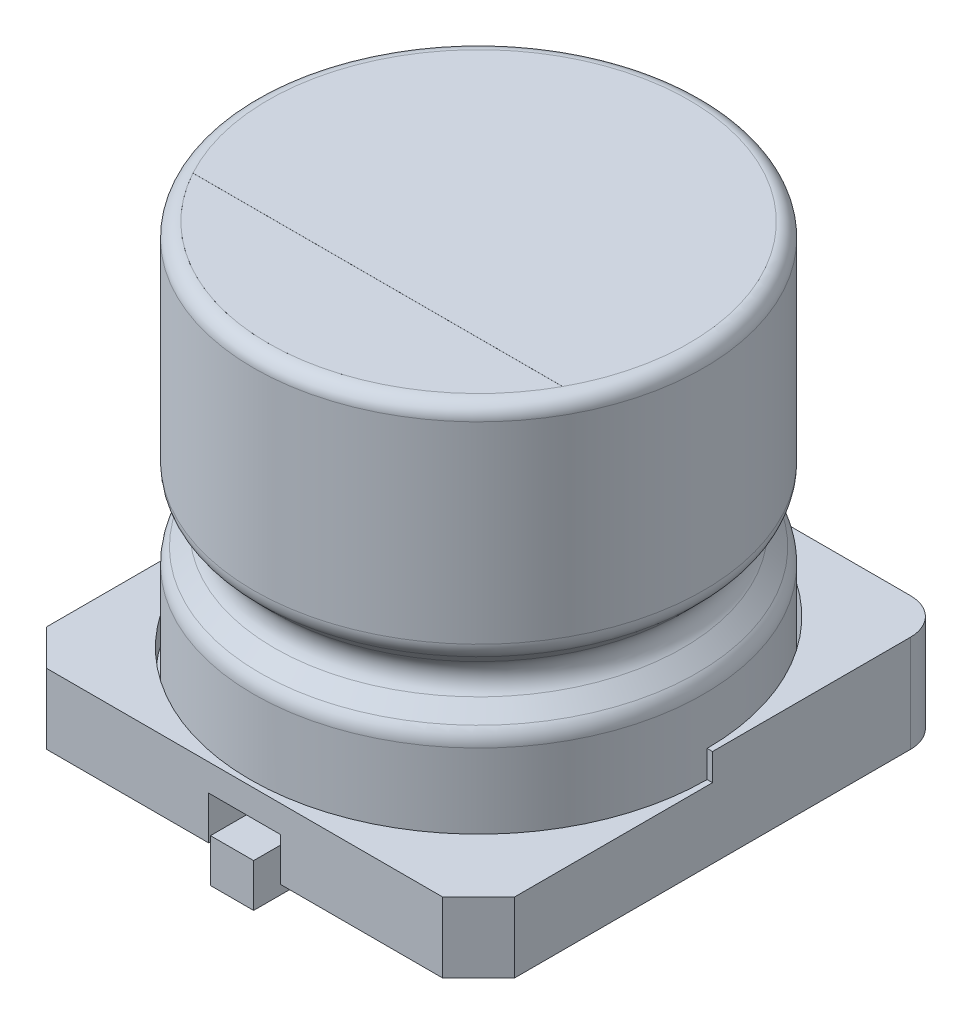
from build123d import *

# Parameters (mm, degrees)
EXTRUDE1_DEPTH     = 1.2
SKETCH3_R          = 6.35
EXTRUDE2_DEPTH     = 1.5
EXTRUDE3_DEPTH     = 0.75
SKETCH5_R          = 0.75
EXTRUDE4_DEPTH     = 0.3
SKETCH7_W          = 1.2
SKETCH7_H          = 1.2
SCALE1_SCALE       = 0.5
CUT_EXTRUDE1_DEPTH = 0.001


with BuildPart() as part:
    # Sketch1 → Revolve1 (revolve)
    with BuildSketch(Plane.XY):
        with BuildLine():
            Line((0, 0), (-6.25, 0))
            Line((-6.25, 0), (-6.25, 2.751471863))
            ThreePointArc((-6.25, 2.751471863), (-6.20432772, 2.981081922), (-6.074264069, 3.175735931))
            Line((-6.074264069, 3.175735931), (-5.674264069, 3.575735931))
            ThreePointArc((-5.674264069, 3.575735931), (-5.498528137, 4), (-5.674264069, 4.424264069))
            Line((-5.674264069, 4.424264069), (-6.074264069, 4.824264069))
            ThreePointArc((-6.074264069, 4.824264069), (-6.20432772, 5.018918078), (-6.25, 5.248528137))
            Line((-6.25, 5.248528137), (-6.25, 10.6))
            ThreePointArc((-6.25, 10.6), (-6.132842712, 10.882842712), (-5.85, 11))
            Line((-5.85, 11), (0, 11))
            Line((0, 11), (0, 0))
        make_face()
    revolve(axis=Axis((0, 11, 0), (0, -1, 0)))

    # Sketch2 → Extrude1 (add)
    with BuildSketch(Plane.XZ):
        with BuildLine():
            Line((-6.5, 5.5), (-5.5, 6.5))
            Line((-5.5, 6.5), (-1, 6.5))
            Line((-1, 6.5), (-1, 1.6))
            Line((-1, 1.6), (1, 1.6))
            Line((1, 1.6), (1, 6.5))
            Line((1, 6.5), (5.5, 6.5))
            Line((5.5, 6.5), (6.5, 5.5))
            Line((6.5, 5.5), (6.5, -5.5))
            ThreePointArc((6.5, -5.5), (6.207106781, -6.207106781), (5.5, -6.5))
            Line((5.5, -6.5), (1, -6.5))
            Line((1, -6.5), (1, -1.6))
            Line((1, -1.6), (-1, -1.6))
            Line((-1, -1.6), (-1, -6.5))
            Line((-1, -6.5), (-5.5, -6.5))
            ThreePointArc((-5.5, -6.5), (-6.207106781, -6.207106781), (-6.5, -5.5))
            Line((-6.5, -5.5), (-6.5, 5.5))
        make_face()
    extrude(amount=EXTRUDE1_DEPTH)

    # Sketch3 → Extrude2 (add)
    with BuildSketch(Plane(origin=(0, 0, 0), x_dir=(1, 0, 0), z_dir=(0, 1, 0))):
        with BuildLine():
            Line((5.5, -6.5), (-5.5, -6.5))
            Line((-5.5, -6.5), (-6.5, -5.5))
            Line((-6.5, -5.5), (-6.5, 5.5))
            ThreePointArc((-6.5, 5.5), (-6.207106781, 6.207106781), (-5.5, 6.5))
            Line((-5.5, 6.5), (5.5, 6.5))
            ThreePointArc((5.5, 6.5), (6.207106781, 6.207106781), (6.5, 5.5))
            Line((6.5, 5.5), (6.5, -5.5))
            Line((6.5, -5.5), (5.5, -6.5))
        make_face()
        Circle(SKETCH3_R, mode=Mode.SUBTRACT)
    extrude(amount=EXTRUDE2_DEPTH)

    # Sketch4 → Extrude3 (cut)
    with BuildSketch(Plane(origin=(0, 1.5, 0), x_dir=(1, 0, 0), z_dir=(0, 1, 0))):
        with BuildLine():
            Line((-6.5, 0), (-6.35, 0))
            ThreePointArc((-6.35, 0), (0, -6.35), (6.35, 0))
            Line((6.35, 0), (6.5, 0))
            Line((6.5, 0), (6.5, -5.5))
            Line((6.5, -5.5), (5.5, -6.5))
            Line((5.5, -6.5), (-5.5, -6.5))
            Line((-5.5, -6.5), (-6.5, -5.5))
            Line((-6.5, -5.5), (-6.5, 0))
        make_face()
    extrude(amount=-EXTRUDE3_DEPTH, mode=Mode.SUBTRACT)

    # Sketch5 → Extrude4 (add)
    with BuildSketch(Plane.XZ.offset(1.2)):
        with Locations((-4, 4)):
            Circle(SKETCH5_R)
        with Locations((4, 4)):
            Circle(SKETCH5_R)
        with Locations((-4, -4)):
            Circle(SKETCH5_R)
        with Locations((4, -4)):
            Circle(SKETCH5_R)
    extrude(amount=EXTRUDE4_DEPTH)

    # Sweep1: sweep along a path in Sketch6
    with BuildLine(Plane(origin=(0, 0, 0), x_dir=(0, 0, -1), z_dir=(1, 0, 0))) as sweep1_path:
        Line((2.7, 0), (2.7, -0.05))
        ThreePointArc((2.7, -0.05), (3.051471863, -0.898528137), (3.9, -1.25))
        Line((3.9, -1.25), (6.85, -1.25))
    # Sketch7 → Sweep1 (sweep)
    with BuildSketch(Plane.XZ):
        with Locations((0, -2.7)):
            Rectangle(SKETCH7_W, SKETCH7_H)
    sweep1 = sweep(path=sweep1_path.line)

    # Mirror1: Sweep1 across plane
    add(sweep1.mirror(Plane.XY))


with BuildPart() as part_1:
    # Scale1: scaled about (0, 4.617982794, -0.053235297)
    add(part.part.scale(SCALE1_SCALE).moved(Location((0, 2.308991397, -0.026617649))))

    # Sketch8 → Cut-Extrude1 (cut)
    with BuildSketch(Plane(origin=(0, 7.808991397, 0), x_dir=(1, 0, 0), z_dir=(0, 1, 0))):
        with BuildLine():
            Line((-2.568194891, -1.373382352), (2.568194891, -1.373382352))
            ThreePointArc((2.568194891, -1.373382352), (0, -2.898382352), (-2.568194891, -1.373382352))
        make_face()
    extrude(amount=-CUT_EXTRUDE1_DEPTH, mode=Mode.SUBTRACT)


solid = part_1.part
